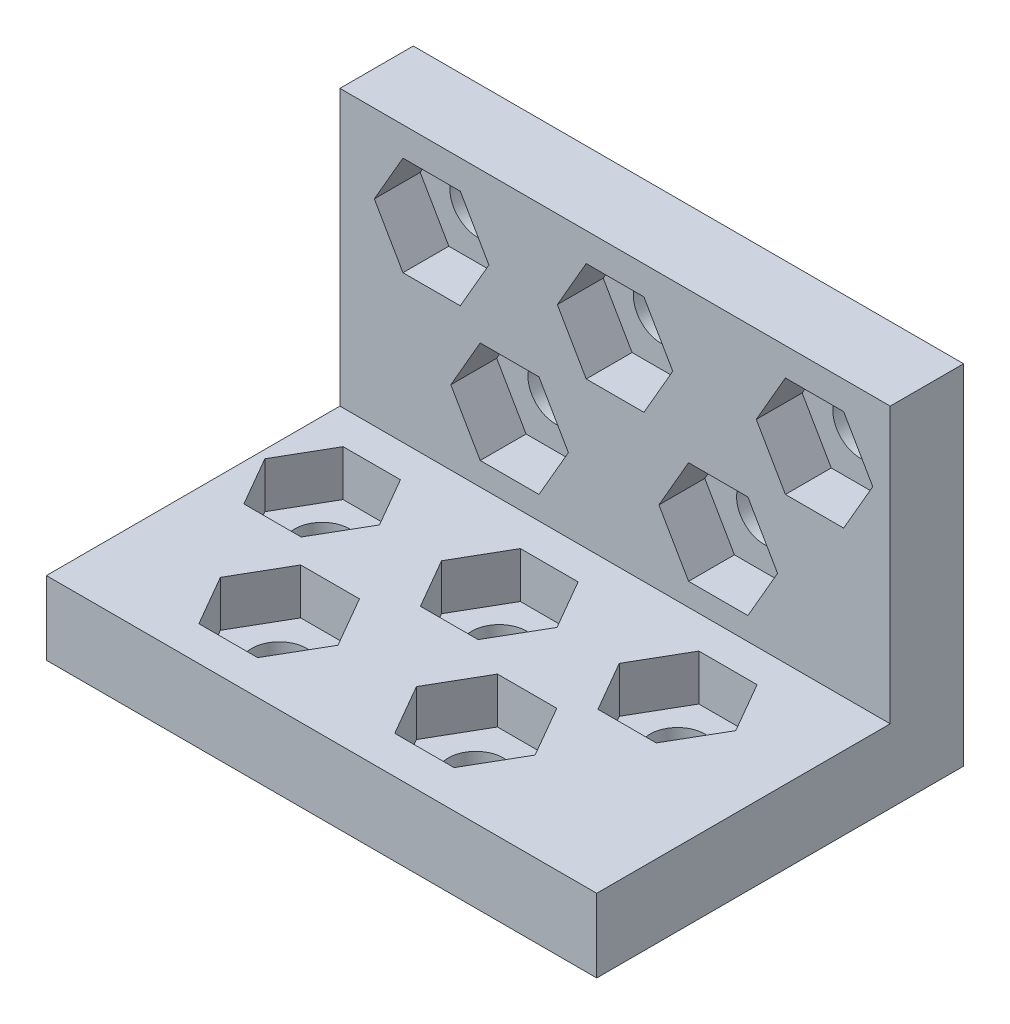
from build123d import *

# Parameters (mm, degrees)
SKETCH1_W               = 30
SKETCH1_H               = 20
BOSS_EXTRUDE1_DEPTH     = 4
SKETCH2_W               = 30
SKETCH2_H               = 4
BOSS_EXTRUDE2_DEPTH     = 15
CUT_EXTRUDE1_DEPTH      = 2.5
SKETCH4_R               = 1.5
CUT_EXTRUDE2_DEPTH      = 19.5
CUT_EXTRUDE2_DEPTH_BACK = 2.5
CUT_EXTRUDE3_DEPTH      = 16
CUT_EXTRUDE3_DEPTH_BACK = 2.5
SKETCH6_R               = 1.5
CUT_EXTRUDE4_DEPTH      = 18.5
CUT_EXTRUDE4_DEPTH_BACK = 2.5


with BuildPart() as part:
    # Sketch1 → Boss-Extrude1 (new body)
    with BuildSketch(Plane(origin=(0, 0, 0), x_dir=(1, 0, 0), z_dir=(0, 1, 0))):
        Rectangle(SKETCH1_W, SKETCH1_H)
    extrude(amount=BOSS_EXTRUDE1_DEPTH)

    # Sketch2 → Boss-Extrude2 (add)
    with BuildSketch(Plane(origin=(0, 4, 0), x_dir=(1, 0, 0), z_dir=(0, 1, 0))):
        with Locations((0, 8)):
            Rectangle(SKETCH2_W, SKETCH2_H)
    extrude(amount=BOSS_EXTRUDE2_DEPTH)

    # Sketch3 → Cut-Extrude1 (cut)
    with BuildSketch(Plane.XY.offset(-6)):
        Polygon((-8.438267522, 12.016236672), (-6.876535044, 14.721236672), (-8.438267522, 17.426236672), (-11.561732478, 17.426236672), (-13.123464956, 14.721236672), (-11.561732478, 12.016236672), align=None)
        Polygon((1.573279484, 11.993045001), (3.146558967, 14.718045001), (1.573279484, 17.443045001), (-1.573279484, 17.443045001), (-3.146558967, 14.718045001), (-1.573279484, 11.993045001), align=None)
        Polygon((12.46124414, 11.971236672), (14.048957381, 14.721236672), (12.46124414, 17.471236672), (9.28581766, 17.471236672), (7.69810442, 14.721236672), (9.28581766, 11.971236672), align=None)
        Polygon((-4.147076238, 5.256448413), (-2.544929241, 8.031448413), (-4.147076238, 10.806448413), (-7.351370232, 10.806448413), (-8.953517229, 8.031448413), (-7.351370232, 5.256448413), align=None)
        Polygon((7.240820874, 5.231448413), (8.857401628, 8.031448413), (7.240820874, 10.831448413), (4.007659367, 10.831448413), (2.391078613, 8.031448413), (4.007659367, 5.231448413), align=None)
    extrude(amount=-CUT_EXTRUDE1_DEPTH, mode=Mode.SUBTRACT)

    # Sketch4 → Cut-Extrude2 (cut, two sides)
    with BuildSketch(Plane.XY.offset(-8.5)) as cut_extrude2_sk:
        with Locations((-10, 14.721236672)):
            Circle(SKETCH4_R)
        with Locations((0, 14.718045001)):
            Circle(SKETCH4_R)
        with Locations((10.8735309, 14.721236672)):
            Circle(SKETCH4_R)
        with Locations((5.624240121, 8.031448413)):
            Circle(SKETCH4_R)
        with Locations((-5.749223235, 8.031448413)):
            Circle(SKETCH4_R)
    extrude(amount=CUT_EXTRUDE2_DEPTH, mode=Mode.SUBTRACT)
    extrude(cut_extrude2_sk.sketch, amount=-CUT_EXTRUDE2_DEPTH_BACK, mode=Mode.SUBTRACT)

    # Sketch5 → Cut-Extrude3 (cut, two sides)
    with BuildSketch(Plane(origin=(0, 4, 0), x_dir=(1, 0, 0), z_dir=(0, 1, 0))) as cut_extrude3_sk:
        Polygon((-9.874222434, -1.236448413), (-8.312489956, 1.468551587), (-9.874222434, 4.173551587), (-12.99768739, 4.173551587), (-14.559419869, 1.468551587), (-12.99768739, -1.236448413), align=None)
        Polygon((-0.207729888, -1.256448413), (1.365549596, 1.468551587), (-0.207729888, 4.193551587), (-3.354288855, 4.193551587), (-4.927568339, 1.468551587), (-3.354288855, -1.256448413), align=None)
        Polygon((9.524140966, -1.281448413), (11.111854207, 1.468551587), (9.524140966, 4.218551587), (6.348714486, 4.218551587), (4.761001245, 1.468551587), (6.348714486, -1.281448413), align=None)
        Polygon((-5.365661597, -8.118028115), (-3.7635146, -5.343028115), (-5.365661597, -2.568028115), (-8.569955591, -2.568028115), (-10.172102588, -5.343028115), (-8.569955591, -8.118028115), align=None)
        Polygon((5.178599497, -7.955553444), (6.795180251, -5.155553444), (5.178599497, -2.355553444), (1.945437989, -2.355553444), (0.328857236, -5.155553444), (1.945437989, -7.955553444), align=None)
    extrude(amount=CUT_EXTRUDE3_DEPTH, mode=Mode.SUBTRACT)
    extrude(cut_extrude3_sk.sketch, amount=-CUT_EXTRUDE3_DEPTH_BACK, mode=Mode.SUBTRACT)

    # Sketch6 → Cut-Extrude4 (cut, two sides)
    with BuildSketch(Plane(origin=(0, 1.5, 0), x_dir=(1, 0, 0), z_dir=(0, 1, 0))) as cut_extrude4_sk:
        with Locations((-11.435954912, 1.468551587)):
            Circle(SKETCH6_R)
        with Locations((-1.781009372, 1.468551587)):
            Circle(SKETCH6_R)
        with Locations((7.936427726, 1.468551587)):
            Circle(SKETCH6_R)
        with Locations((3.562018743, -5.155553444)):
            Circle(SKETCH6_R)
        with Locations((-6.967808594, -5.343028115)):
            Circle(SKETCH6_R)
    extrude(amount=CUT_EXTRUDE4_DEPTH, mode=Mode.SUBTRACT)
    extrude(cut_extrude4_sk.sketch, amount=-CUT_EXTRUDE4_DEPTH_BACK, mode=Mode.SUBTRACT)


solid = part.part
